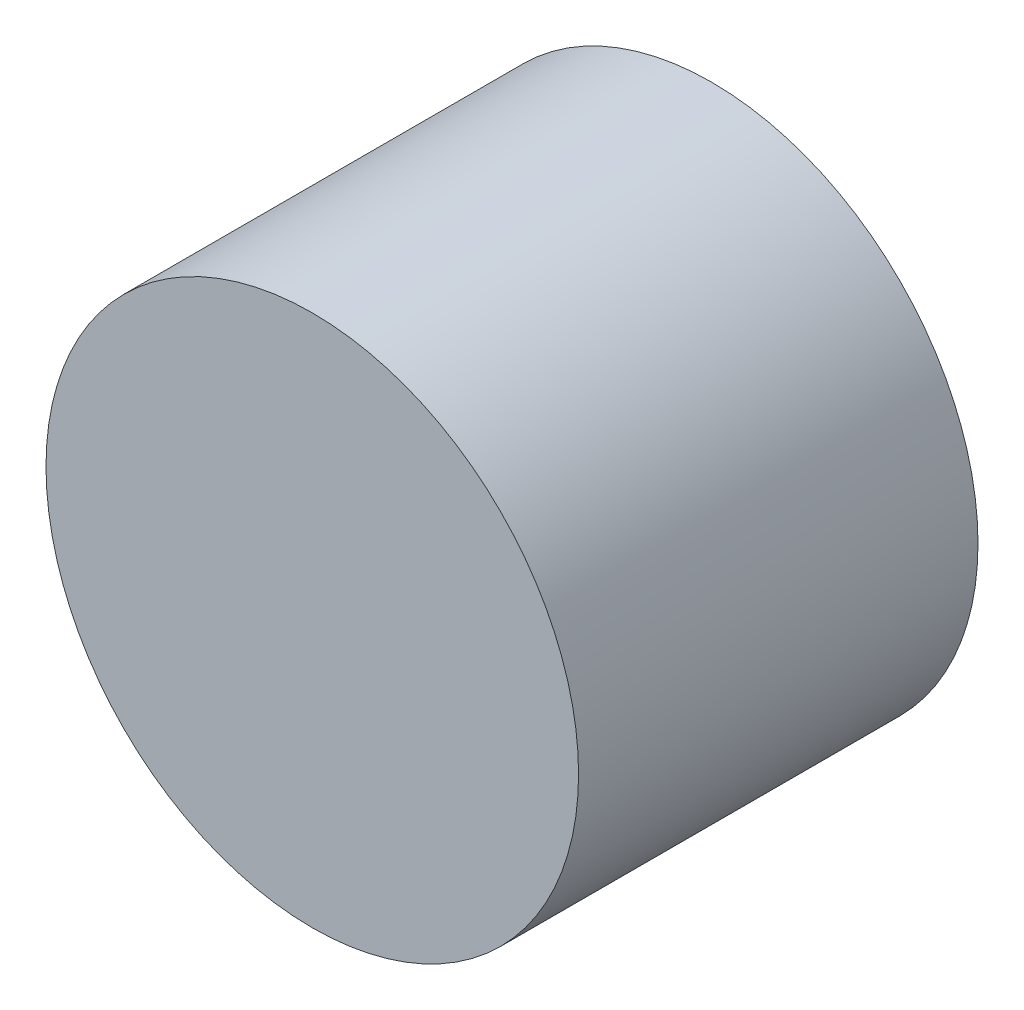
from build123d import *

# Parameters (mm, degrees)
CROQUIS1_R              = 10
SALIENTE_EXTRUIR1_DEPTH = 15


with BuildPart() as part:
    # Croquis1 → Saliente-Extruir1 (new body)
    with BuildSketch(Plane.XY):
        Circle(CROQUIS1_R)
    extrude(amount=SALIENTE_EXTRUIR1_DEPTH)


solid = part.part
